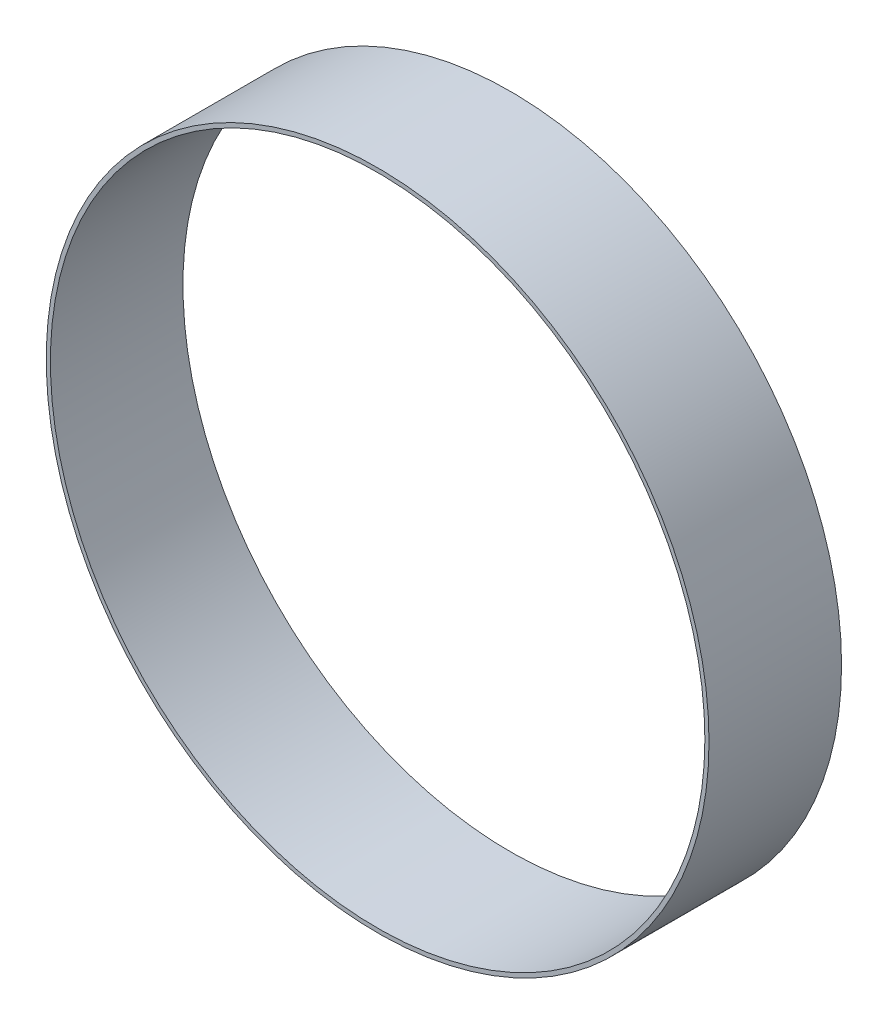
from build123d import *

# Parameters (mm, degrees)
SKETCH1_R           = 127
BOSS_EXTRUDE1_DEPTH = 50.8
SKETCH2_R           = 125.4125
CUT_EXTRUDE1_DEPTH  = 50.8


with BuildPart() as part:
    # Sketch1 → Boss-Extrude1 (new body)
    with BuildSketch(Plane.XY):
        Circle(SKETCH1_R)
    extrude(amount=BOSS_EXTRUDE1_DEPTH)

    # Sketch2 → Cut-Extrude1 (cut)
    with BuildSketch(Plane.XY.offset(50.8)):
        Circle(SKETCH2_R)
    extrude(amount=-CUT_EXTRUDE1_DEPTH, mode=Mode.SUBTRACT)


solid = part.part
